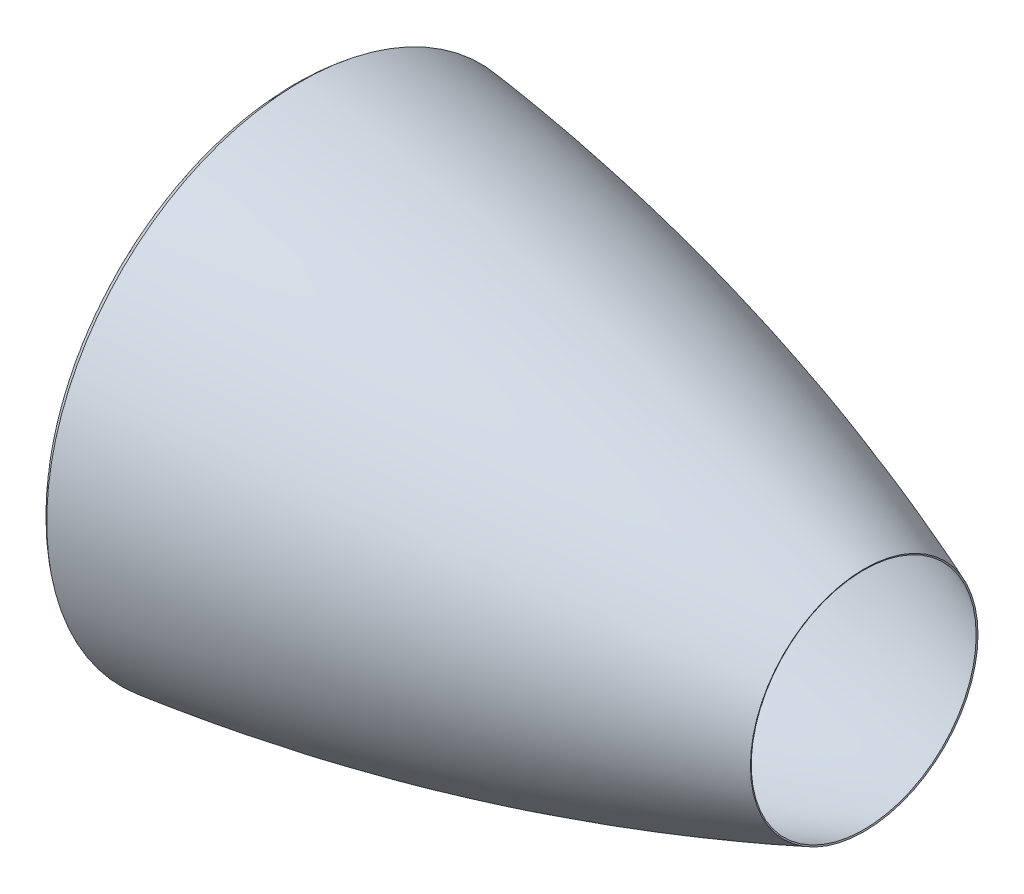
from build123d import *

# Parameters (mm, degrees)
THICKEN1_T1 = 5


with BuildPart() as body_1:
    # Surface-Revolve1: a surface, the sketch's curves turned about an axis
    with BuildLine(Plane.XY, mode=Mode.PRIVATE) as surface_revolve1_1_path:
        Line((71.070407556, 850), (46.070407556, 850))
        Line((46.070407556, 850), (25, 830))
        Line((25, 830), (0, 830))
        add(Edge.make_bspline(
            [(0, 830), (-61.909249319, 852.027455518), (0, 898.860965047)],
            knots=[0, 0, 0, 1, 1, 1], degree=2))
        add(Edge.make_bspline(
            [(0, 898.860965047), (1027.017719494, 781.491587626), (2000, 400)],
            knots=[0, 0, 0, 1, 1, 1], degree=2))
    surface_revolve1_1 = Shell.revolve(surface_revolve1_1_path.wire(), 360, Axis((0, 0, 0), (1, 0, 0)))
    add(Solid.thicken(surface_revolve1_1, THICKEN1_T1))


solid = body_1.part
